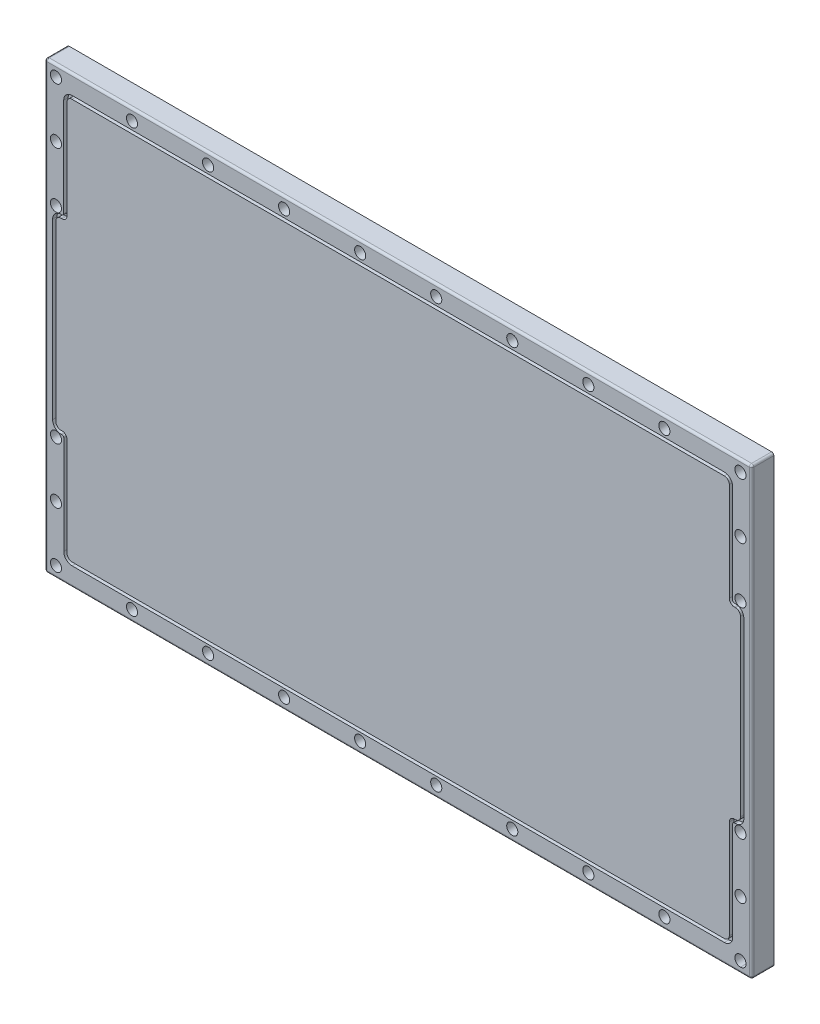
from build123d import *

# Parameters (mm, degrees)
SKETCH2_W            = 635
SKETCH2_H            = 400
BOSS_EXTRUDE1_DEPTH  = 10
SKETCH4_R            = 5
CUT_EXTRUDE1_DEPTH   = 20
LPATTERN1_COUNT      = 10
LPATTERN1_PITCH      = 68.33
LPATTERN1_COUNT_DIR2 = 2
LPATTERN1_PITCH_DIR2 = 380
LPATTERN3_COUNT      = 3
LPATTERN3_PITCH      = 50
LPATTERN3_COUNT_DIR2 = 2
LPATTERN3_PITCH_DIR2 = 615
LPATTERN4_COUNT      = 2
LPATTERN4_PITCH      = 330
SKETCH7_R            = 5
CUT_EXTRUDE5_DEPTH   = 20
LPATTERN7_COUNT      = 2
LPATTERN7_PITCH      = 615
LPATTERN7_COUNT_DIR2 = 2
LPATTERN7_PITCH_DIR2 = 50
CUT_EXTRUDE6_DEPTH   = 4
FILLET1_R            = 2


with BuildPart() as part:
    # Sketch2 → Boss-Extrude1 (new body, symmetric)
    with BuildSketch(Plane.XY):
        with Locations((317.5, 200)):
            Rectangle(SKETCH2_W, SKETCH2_H)
    extrude(amount=BOSS_EXTRUDE1_DEPTH, both=True)

    # Sketch4 → Cut-Extrude1 (cut)
    with BuildSketch(Plane.XY.offset(10)):
        with Locations((10, 10)):
            Circle(SKETCH4_R)
    cut_extrude1 = extrude(amount=-CUT_EXTRUDE1_DEPTH, mode=Mode.SUBTRACT)

    # LPattern1: Cut-Extrude1 10 × 2
    with Locations(*[(i * LPATTERN1_PITCH, j * LPATTERN1_PITCH_DIR2, 0) for i in range(LPATTERN1_COUNT) for j in range(LPATTERN1_COUNT_DIR2) if (i, j) != (0, 0)]):
        add(cut_extrude1, mode=Mode.SUBTRACT)

    # LPattern3: Cut-Extrude1 3 × 2
    with Locations(*[(j * LPATTERN3_PITCH_DIR2, i * LPATTERN3_PITCH, 0) for i in range(LPATTERN3_COUNT) for j in range(LPATTERN3_COUNT_DIR2) if (i, j) != (0, 0)]):
        add(cut_extrude1, mode=Mode.SUBTRACT)

    # LPattern4: Cut-Extrude1 ×2
    with Locations(*[(0, i * LPATTERN4_PITCH, 0) for i in range(1, LPATTERN4_COUNT)]):
        add(cut_extrude1, mode=Mode.SUBTRACT)

    # Sketch7 → Cut-Extrude5 (cut)
    with BuildSketch(Plane.XY.offset(10)):
        with Locations((625, 340)):
            Circle(SKETCH7_R)
    cut_extrude5 = extrude(amount=-CUT_EXTRUDE5_DEPTH, mode=Mode.SUBTRACT)

    # LPattern7: Cut-Extrude5 2 × 2
    with Locations(*[(-i * LPATTERN7_PITCH, -j * LPATTERN7_PITCH_DIR2, 0) for i in range(LPATTERN7_COUNT) for j in range(LPATTERN7_COUNT_DIR2) if (i, j) != (0, 0)]):
        add(cut_extrude5, mode=Mode.SUBTRACT)

    # Sketch8 → Cut-Extrude6 (cut)
    with BuildSketch(Plane.XY.offset(10)):
        with BuildLine():
            Line((16.97, 375.5), (16.97, 287))
            ThreePointArc((16.97, 287), (16.530660172, 285.939339828), (15.47, 285.5))
            Line((15.47, 285.5), (14.47, 285.5))
            ThreePointArc((14.47, 285.5), (9.166699141, 283.303300859), (6.97, 278))
            Line((6.97, 278), (6.97, 122))
            ThreePointArc((6.97, 122), (9.166699141, 116.696699141), (14.47, 114.5))
            Line((14.47, 114.5), (15.5, 114.5))
            ThreePointArc((15.5, 114.5), (16.560660172, 114.060660172), (17, 113))
            Line((17, 113), (17, 24.5))
            ThreePointArc((17, 24.5), (19.196699141, 19.196699141), (24.5, 17))
            Line((24.5, 17), (610.5, 17))
            ThreePointArc((610.5, 17), (615.803300859, 19.196699141), (618, 24.5))
            Line((618, 24.5), (618, 113))
            ThreePointArc((618, 113), (618.439339828, 114.060660172), (619.5, 114.5))
            Line((619.5, 114.5), (620.5, 114.5))
            ThreePointArc((620.5, 114.5), (625.803300859, 116.696699141), (628, 122))
            Line((628, 122), (628, 278))
            ThreePointArc((628, 278), (625.803300859, 283.303300859), (620.5, 285.5))
            Line((620.5, 285.5), (619.47, 285.5))
            ThreePointArc((619.47, 285.5), (618.409339828, 285.939339828), (617.97, 287))
            Line((617.97, 287), (617.97, 375.5))
            ThreePointArc((617.97, 375.5), (615.773300859, 380.803300859), (610.47, 383))
            Line((610.47, 383), (24.47, 383))
            ThreePointArc((24.47, 383), (19.166699141, 380.803300859), (16.97, 375.5))
        make_face()
        with BuildLine():
            Line((20, 113), (20, 24.5))
            ThreePointArc((20, 24.5), (21.318019485, 21.318019485), (24.5, 20))
            Line((24.5, 20), (610.5, 20))
            ThreePointArc((610.5, 20), (613.681980515, 21.318019485), (615, 24.5))
            Line((615, 24.5), (615, 113))
            ThreePointArc((615, 113), (616.318019485, 116.181980515), (619.5, 117.5))
            Line((619.5, 117.5), (620.5, 117.5))
            ThreePointArc((620.5, 117.5), (623.681980515, 118.818019485), (625, 122))
            Line((625, 122), (625, 278))
            ThreePointArc((625, 278), (623.681980515, 281.181980515), (620.5, 282.5))
            Line((620.5, 282.5), (619.47, 282.5))
            ThreePointArc((619.47, 282.5), (616.288019485, 283.818019485), (614.97, 287))
            Line((614.97, 287), (614.97, 375.5))
            ThreePointArc((614.97, 375.5), (613.651980515, 378.681980515), (610.47, 380))
            Line((610.47, 380), (24.47, 380))
            ThreePointArc((24.47, 380), (21.288019485, 378.681980515), (19.97, 375.5))
            Line((19.97, 375.5), (19.97, 287))
            ThreePointArc((19.97, 287), (18.651980515, 283.818019485), (15.47, 282.5))
            Line((15.47, 282.5), (14.47, 282.5))
            ThreePointArc((14.47, 282.5), (11.288019485, 281.181980515), (9.97, 278))
            Line((9.97, 278), (9.97, 122))
            ThreePointArc((9.97, 122), (11.288019485, 118.818019485), (14.47, 117.5))
            Line((14.47, 117.5), (15.5, 117.5))
            ThreePointArc((15.5, 117.5), (18.681980515, 116.181980515), (20, 113))
        make_face(mode=Mode.SUBTRACT)
    extrude(amount=-CUT_EXTRUDE6_DEPTH, mode=Mode.SUBTRACT)

    # Fillet1
    fillet1_edges = [part.edges().sort_by_distance(p)[0] for p in [
        (635, 200, 10),
        (317.5, 400, 10),
        (0, 200, 10),
        (0, 400, 0),
        (635, 400, 0),
        (635, 0, 0),
        (0, 0, 0),
        (317.5, 0, 10),
    ]]
    fillet(fillet1_edges, radius=FILLET1_R)


solid = part.part
